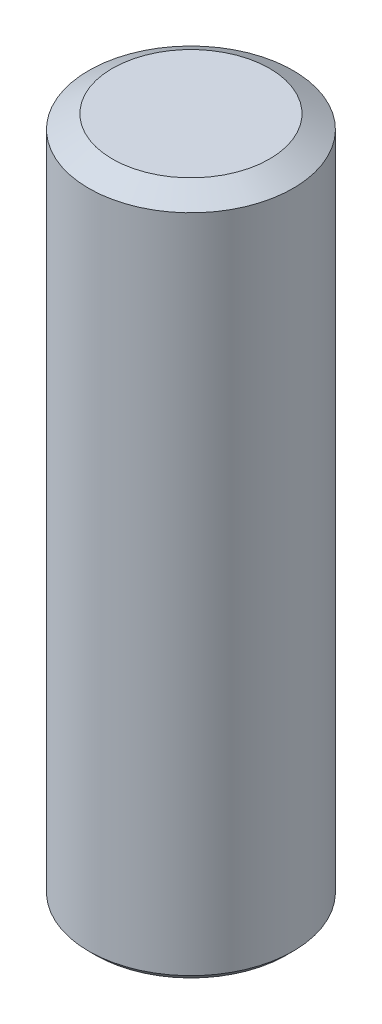
from build123d import *

# Parameters (mm, degrees)
CROQUIS1_R              = 1.5
SALIENTE_EXTRUIR1_DEPTH = 10
CORTAR_EXTRUIR1_DEPTH   = 2
CHAFL_N2_SIZE           = 0.1
CHAFL_N3_SIZE           = 0.2
CHAFL_N3_SIZE2          = 0.346410162


with BuildPart() as part:
    # Croquis1 → Saliente-Extruir1 (new body)
    with BuildSketch(Plane(origin=(0, 0, 0), x_dir=(1, 0, 0), z_dir=(0, 1, 0))):
        Circle(CROQUIS1_R)
    extrude(amount=SALIENTE_EXTRUIR1_DEPTH)

    # Croquis2 → Cortar-Extruir1 (cut)
    with BuildSketch(Plane.XZ):
        Polygon((0.433012702, 0.75), (-0.433012702, 0.75), (-0.866025404, 0), (-0.433012702, -0.75), (0.433012702, -0.75), (0.866025404, 0), align=None)
    extrude(amount=-CORTAR_EXTRUIR1_DEPTH, mode=Mode.SUBTRACT)

    # Chaflán2
    chafl_n2_edges = [part.edges().sort_by_distance(p)[0] for p in [
        (-1.5, 0, 0),
    ]]
    chamfer(chafl_n2_edges, length=CHAFL_N2_SIZE)

    # Chaflán3
    chafl_n3_edges = [part.edges().sort_by_distance(p)[0] for p in [
        (-1.5, 10, 0),
    ]]
    chafl_n3_side = [part.faces().sort_by_distance(p)[0] for p in [
        (-1.5, 5.05, 0),
    ]]
    chamfer(chafl_n3_edges, length=CHAFL_N3_SIZE, length2=CHAFL_N3_SIZE2, reference=chafl_n3_side[0])


solid = part.part
